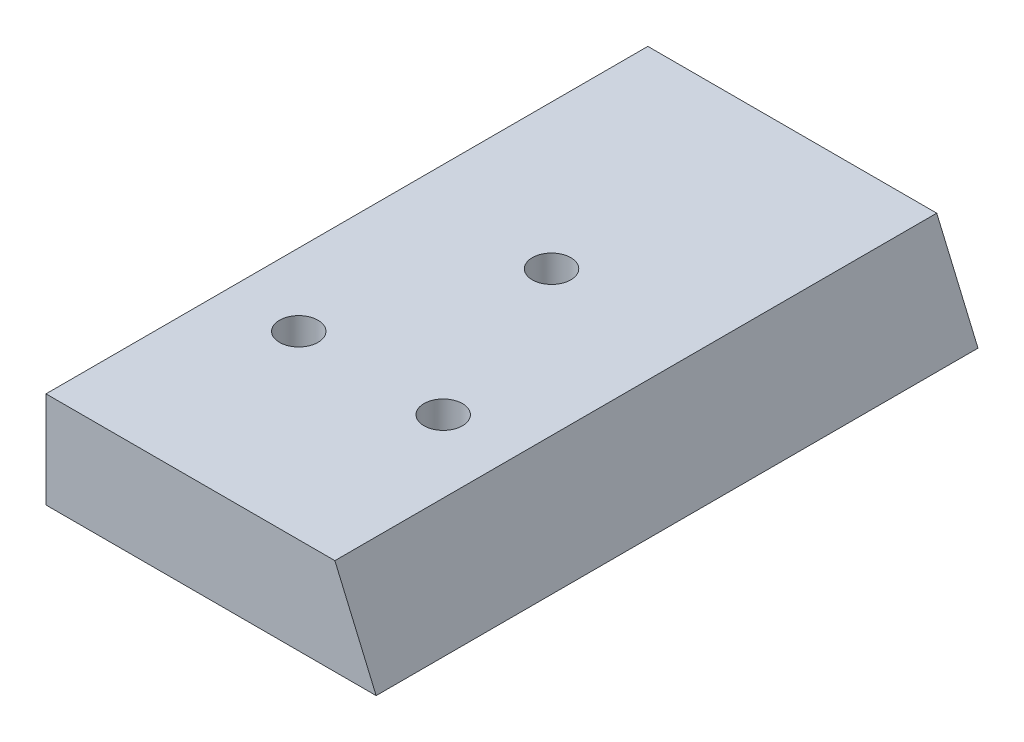
from build123d import *

# Parameters (mm, degrees)
SALIENTE_EXTRUIR1_DEPTH = 50
CORTAR_EXTRUIR1_REACH   = 10
CROQUIS3_R              = 1.6
CROQUIS6_R              = 1.9
CORTAR_EXTRUIR3_DEPTH   = 10


with BuildPart() as part:
    # Croquis1 → Saliente-Extruir1 (new body)
    with BuildSketch(Plane.XY):
        Polygon((45.761533754, 80.324875029), (69.761533754, 80.324875029), (73.190105182, 72.324875029), (45.761533754, 72.324875029), align=None)
    extrude(amount=SALIENTE_EXTRUIR1_DEPTH)

    # Croquis3 → Cortar-Extruir1 (cut, up to next)
    with BuildSketch(Plane.XZ.offset(-72.324875029), mode=Mode.PRIVATE) as cortar_extruir1_sk1:
        with Locations((63.761533754, 35)):
            Circle(CROQUIS3_R)
    cortar_extruir1_tool1 = extrude(cortar_extruir1_sk1.sketch, amount=-CORTAR_EXTRUIR1_REACH, mode=Mode.PRIVATE) & part.part
    add(cortar_extruir1_tool1.solids().sort_by_distance((63.761534, 72.324875, 35))[0], mode=Mode.SUBTRACT)
    # Croquis3 → Cortar-Extruir1 (cut, up to next)
    with BuildSketch(Plane.XZ.offset(-72.324875029), mode=Mode.PRIVATE) as cortar_extruir1_sk2:
        with Locations((57.761533754, 20)):
            Circle(CROQUIS3_R)
    cortar_extruir1_tool2 = extrude(cortar_extruir1_sk2.sketch, amount=-CORTAR_EXTRUIR1_REACH, mode=Mode.PRIVATE) & part.part
    add(cortar_extruir1_tool2.solids().sort_by_distance((57.761534, 72.324875, 20))[0], mode=Mode.SUBTRACT)
    # Croquis3 → Cortar-Extruir1 (cut, up to next)
    with BuildSketch(Plane.XZ.offset(-72.324875029), mode=Mode.PRIVATE) as cortar_extruir1_sk3:
        with Locations((51.761533754, 35)):
            Circle(CROQUIS3_R)
    cortar_extruir1_tool3 = extrude(cortar_extruir1_sk3.sketch, amount=-CORTAR_EXTRUIR1_REACH, mode=Mode.PRIVATE) & part.part
    add(cortar_extruir1_tool3.solids().sort_by_distance((51.761534, 72.324875, 35))[0], mode=Mode.SUBTRACT)

    # Croquis6 → Cortar-Extruir3 (cut)
    with BuildSketch(Plane(origin=(0, 0, 0), x_dir=(-1, 0, 0), z_dir=(0, 0, -1))):
        with Locations((-63.761533754, 76.324875029)):
            Circle(CROQUIS6_R)
        with Locations((-51.761533754, 76.324875029)):
            Circle(CROQUIS6_R)
    extrude(amount=-CORTAR_EXTRUIR3_DEPTH, mode=Mode.SUBTRACT)


solid = part.part
